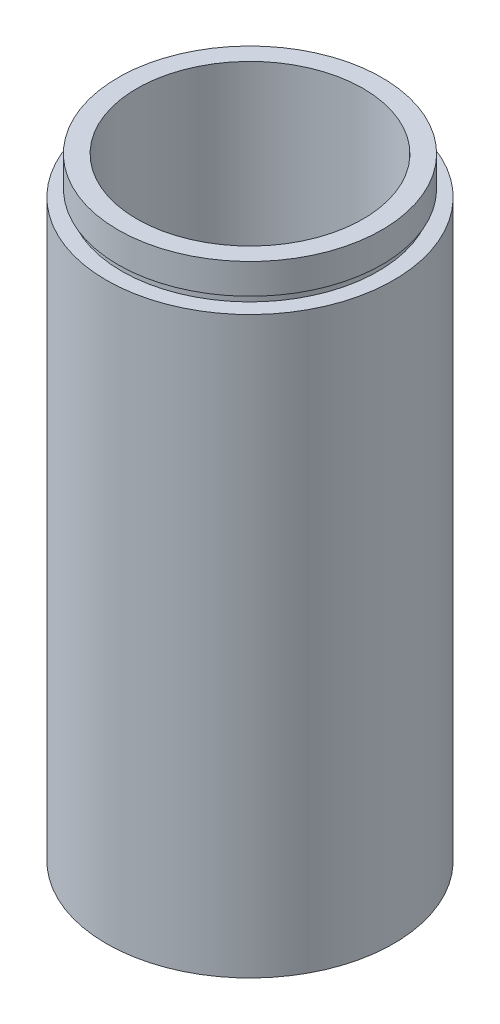
from build123d import *


with BuildPart() as part:
    # 草图1 → 旋转1 (revolve)
    with BuildSketch(Plane.XY, mode=Mode.PRIVATE) as revolve_1_sk:
        Polygon((19.05, 0), (19.05, 76.2), (17, 76.2), (17, 77.2), (17.5, 77.2), (17.5, 81.2), (15, 81.2), (15, 5.5), (17.6, 5.5), (17.6, 4.5), (17, 4.5), (17, 0), align=None)
    revolve(revolve_1_sk.sketch.rotate(Axis((0, 161.376166943, 0), (0, -1, 0)), 90), axis=Axis((0, 161.376166943, 0), (0, -1, 0)))  # turned: the seam where the file's is


solid = part.part
